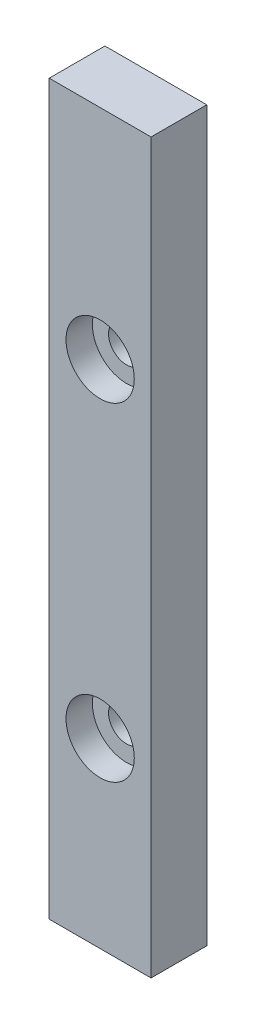
from build123d import *

# Parameters (mm, degrees)
SKETCH1_W                 = 8.5
SKETCH1_H                 = 60.8
BOSS_EXTRUDE1_DEPTH       = 4.65
F_3_0MM_DOWEL_HOLE1_D     = 3
F_3_0MM_DOWEL_HOLE1_DEPTH = 5
F_3_0MM_DOWEL_HOLE1_TIP   = 0.901290929
SKETCH6_R                 = 2.85
CUT_EXTRUDE1_DEPTH        = 2.2


with BuildPart() as part:
    # Sketch1 → Boss-Extrude1 (new body)
    with BuildSketch(Plane.XY):
        with Locations((4.25, -30.4)):
            Rectangle(SKETCH1_W, SKETCH1_H)
    extrude(amount=BOSS_EXTRUDE1_DEPTH)

    # Ø3.0mm Dowel Hole1
    with Locations(Plane.XY.offset(4.65)):
        with Locations((4.25, -18.2), (4.25, -45.6)):
            Hole(F_3_0MM_DOWEL_HOLE1_D / 2, depth=F_3_0MM_DOWEL_HOLE1_DEPTH)
            with Locations((0, 0, -(F_3_0MM_DOWEL_HOLE1_DEPTH + F_3_0MM_DOWEL_HOLE1_TIP / 2))):  # 118° drill point
                Cone(0, F_3_0MM_DOWEL_HOLE1_D / 2, F_3_0MM_DOWEL_HOLE1_TIP, mode=Mode.SUBTRACT)

    # Sketch6 → Cut-Extrude1 (cut)
    with BuildSketch(Plane.XY.offset(4.65)):
        with Locations((4.25, -18.2)):
            Circle(SKETCH6_R)
        with Locations((4.25, -45.6)):
            Circle(SKETCH6_R)
    extrude(amount=-CUT_EXTRUDE1_DEPTH, mode=Mode.SUBTRACT)


solid = part.part
